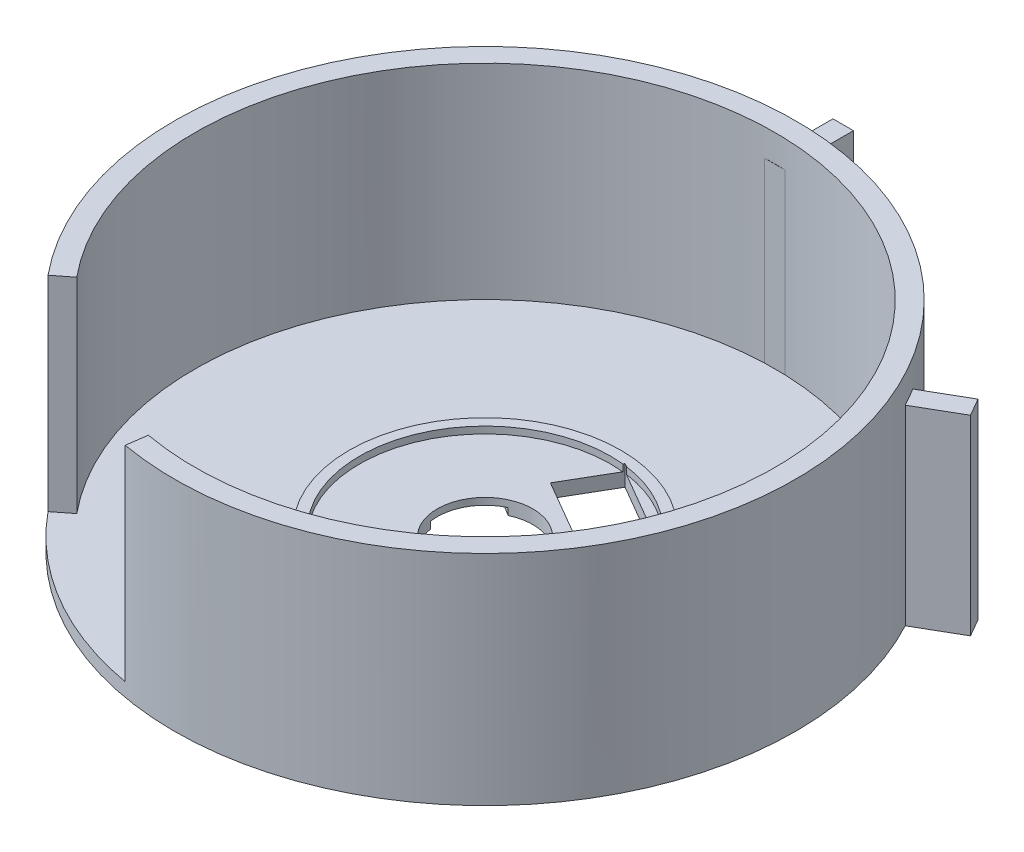
from build123d import *

# Parameters (mm, degrees)
SKETCH1_R                = 45.5
SKETCH1_R_2              = 42.5
BOSS_EXTRUDE1_DEPTH      = 32
SKETCH2_R                = 45.5
BOSS_EXTRUDE2_DEPTH      = 2
SKETCH3_R                = 7
CUT_EXTRUDE1_DEPTH       = 2
SKETCH7_W                = 3
SKETCH7_H                = 10
BOSS_EXTRUDE4_DEPTH      = 26
BOSS_EXTRUDE4_DEPTH_BACK = 2
SKETCH8_R                = 19.890165718
SKETCH8_R_2              = 18.390165718
BOSS_EXTRUDE5_DEPTH      = 1
CUT_EXTRUDE4_DEPTH       = 5.5
CUT_EXTRUDE5_DEPTH       = 58.5
CUT_EXTRUDE6_DEPTH       = 1


with BuildPart() as part:
    # Sketch1 → Boss-Extrude1 (new body)
    with BuildSketch(Plane(origin=(0, 0, 0), x_dir=(1, 0, 0), z_dir=(0, 1, 0))):
        Circle(SKETCH1_R)
        Circle(SKETCH1_R_2, mode=Mode.SUBTRACT)
    extrude(amount=BOSS_EXTRUDE1_DEPTH)

    # Sketch2 → Boss-Extrude2 (add)
    with BuildSketch(Plane.XZ):
        Circle(SKETCH2_R)
    extrude(amount=-BOSS_EXTRUDE2_DEPTH)

    # Sketch3 → Cut-Extrude1 (cut)
    with BuildSketch(Plane(origin=(0, 2, 0), x_dir=(1, 0, 0), z_dir=(0, 1, 0))):
        Circle(SKETCH3_R)
    extrude(amount=-CUT_EXTRUDE1_DEPTH, mode=Mode.SUBTRACT)

    # Sketch7 → Boss-Extrude4 (add, two sides)
    with BuildSketch(Plane(origin=(0, 2, 0), x_dir=(1, 0, 0), z_dir=(0, 1, 0))) as boss_extrude4_sk:
        with Locations((0, 47.473521163)):
            Rectangle(SKETCH7_W, SKETCH7_H)
        Polygon((46.193402353, 24.937722476), (37.533148315, 19.937722476), (36.033148315, 22.535798687), (44.693402353, 27.535798687), align=None)
    extrude(amount=BOSS_EXTRUDE4_DEPTH)
    extrude(boss_extrude4_sk.sketch, amount=-BOSS_EXTRUDE4_DEPTH_BACK)

    # Sketch8 → Boss-Extrude5 (add)
    with BuildSketch(Plane(origin=(0, 2, 0), x_dir=(1, 0, 0), z_dir=(0, 1, 0))):
        Circle(SKETCH8_R)
        Circle(SKETCH8_R_2, mode=Mode.SUBTRACT)
    extrude(amount=BOSS_EXTRUDE5_DEPTH)

    # Sketch10 → Cut-Extrude4 (cut)
    with BuildSketch(Plane.XZ):
        Polygon((2.016687189, -18.494703278), (14.981867268, -10.951222284), (10.958677405, -4.036459575), (-2.006502675, -11.579940569), align=None)
    extrude(amount=-CUT_EXTRUDE4_DEPTH, mode=Mode.SUBTRACT)

    # Sketch11 → Cut-Extrude5 (cut)
    with BuildSketch(Plane(origin=(0, 2, 0), x_dir=(1, 0, 0), z_dir=(0, 1, 0))):
        Polygon((-32.606600292, -26.874098434), (-35.165226496, -28.87311631), (-33.824988888, -37.754161376), (-11.7382848, -48.772412552), (-7.925983096, -44.804338986), (-7.495155029, -41.738838001), (-9.978475631, -35.419229659), (-25.965270809, -26.874098434), align=None)
    extrude(amount=CUT_EXTRUDE5_DEPTH, mode=Mode.SUBTRACT)

    # Sketch12 → Cut-Extrude6 (cut)
    with BuildSketch(Plane.XZ):
        Polygon((-6.912265346, 1.104802147), (-24.20763883, -9.480307189), (-19.814483018, -16.658435267), (-2.519109534, -6.073325931), align=None)
    extrude(amount=-CUT_EXTRUDE6_DEPTH, mode=Mode.SUBTRACT)


solid = part.part
